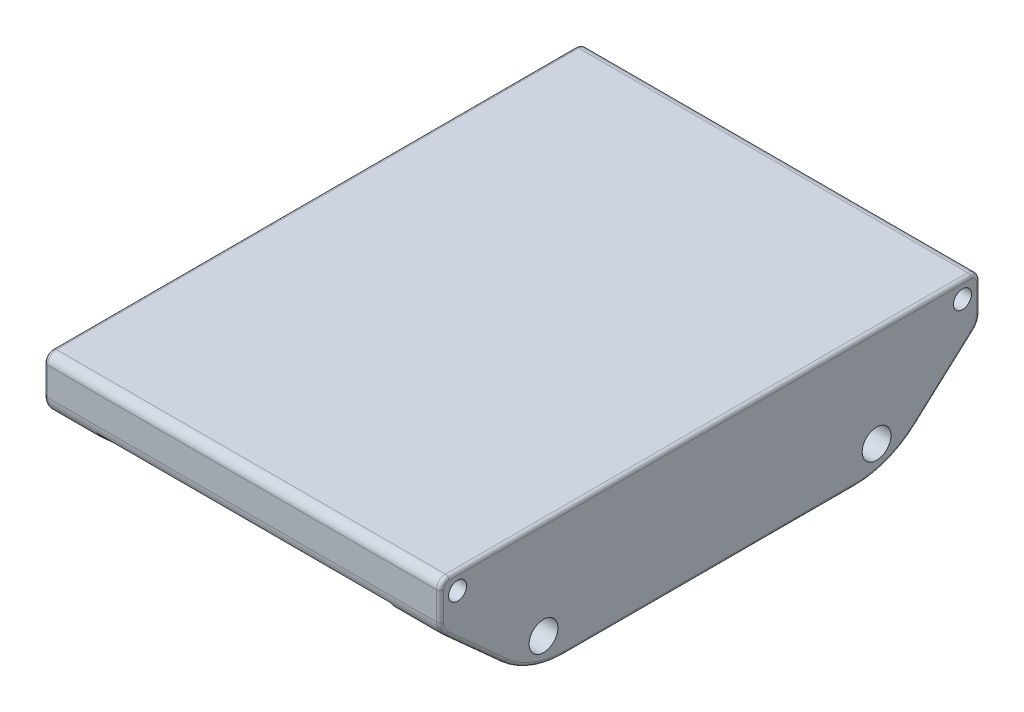
from build123d import *

# Parameters (mm, degrees)
SKETCH1_W               = 220
SKETCH1_H               = 300
BOSS_EXTRUDE1_DEPTH     = 70
SKETCH2_R               = 5
SKETCH2_R_2             = 8
CUT_EXTRUDE1_DEPTH      = 221
CHAMFER1_SIZE           = 50
CHAMFER1_SIZE2          = 45.020202215
FILLET1_R               = 5
FILLET2_R               = 10
FILLET3_R               = 50
SKETCH3_W               = 160
SKETCH3_H               = 45
CUT_EXTRUDE2_DEPTH      = 151
CUT_EXTRUDE2_DEPTH_BACK = 151
FILLET4_R               = 2
FILLET5_R               = 2


with BuildPart() as part:
    # Sketch1 → Boss-Extrude1 (new body)
    with BuildSketch(Plane(origin=(0, 0, 0), x_dir=(1, 0, 0), z_dir=(0, 1, 0))):
        Rectangle(SKETCH1_W, SKETCH1_H)
    extrude(amount=BOSS_EXTRUDE1_DEPTH)

    # Sketch2 → Cut-Extrude1 (cut, through all)
    with BuildSketch(Plane.ZY.offset(110)):
        with Locations((-140.194362572, 60.620694634)):
            Circle(SKETCH2_R)
        with Locations((-92.5, 15)):
            Circle(SKETCH2_R_2)
        with Locations((92.5, 15)):
            Circle(SKETCH2_R_2)
        with Locations((140.194362572, 60.620694634)):
            Circle(SKETCH2_R)
    extrude(amount=-CUT_EXTRUDE1_DEPTH, mode=Mode.SUBTRACT)

    # Chamfer1
    chamfer1_edges = [part.edges().sort_by_distance(p)[0] for p in [
        (0, 0, -150),
        (0, 0, 150),
    ]]
    chamfer1_side = [part.faces().sort_by_distance(p)[0] for p in [
        (0, 0, 0),
    ]]
    chamfer(chamfer1_edges, length=CHAMFER1_SIZE, length2=CHAMFER1_SIZE2, reference=chamfer1_side[0])

    # Fillet1
    fillet1_edges = [part.edges().sort_by_distance(p)[0] for p in [
        (0, 70, -150),
        (0, 70, 150),
    ]]
    fillet(fillet1_edges, radius=FILLET1_R)

    # Fillet2
    fillet2_edges = [part.edges().sort_by_distance(p)[0] for p in [
        (0, 45.020202215, 150),
        (0, 45.020202215, -150),
    ]]
    fillet(fillet2_edges, radius=FILLET2_R)

    # Fillet3
    fillet3_edges = [part.edges().sort_by_distance(p)[0] for p in [
        (0, 0, -100),
        (0, 0, 100),
    ]]
    fillet(fillet3_edges, radius=FILLET3_R)

    # Sketch3 → Cut-Extrude2 (cut, two sides)
    with BuildSketch(Plane.XY) as cut_extrude2_sk:
        with Locations((0, 22.5)):
            Rectangle(SKETCH3_W, SKETCH3_H)
    extrude(amount=CUT_EXTRUDE2_DEPTH, mode=Mode.SUBTRACT)
    extrude(cut_extrude2_sk.sketch, amount=-CUT_EXTRUDE2_DEPTH_BACK, mode=Mode.SUBTRACT)

    # Fillet4
    fillet4_edges = [part.edges().sort_by_distance(p)[0] for p in [
        (-80, 3.320978675, 98.725195725),
        (80, 3.320978675, 98.725195725),
        (80, 43.41487437, -147.956463044),
        (80, 27.44189977, -130.477317315),
        (80, 3.320978675, -98.725195725),
        (80, 27.44189977, 130.477317315),
        (80, 43.41487437, 147.956463044),
        (-80, 0, 0),
        (-80, 27.44189977, -130.477317315),
        (-80, 43.41487437, -147.956463044),
        (-80, 3.320978675, -98.725195725),
        (-80, 43.41487437, 147.956463044),
        (-80, 27.44189977, 130.477317315),
        (80, 0, 0),
    ]]
    fillet(fillet4_edges, radius=FILLET4_R)

    # Fillet5
    fillet5_edges = [part.edges().sort_by_distance(p)[0] for p in [
        (-110, 70, 0),
        (110, 70, 0),
        (-110, 57.236244534, 150),
        (-110, 57.236244534, -150),
        (-110, 68.535533906, 148.535533906),
        (-110, 68.535533906, -148.535533906),
        (110, 57.236244534, -150),
        (110, 57.236244534, 150),
        (110, 68.535533906, 148.535533906),
        (110, 68.535533906, -148.535533906),
        (-110, 27.44189977, -130.477317315),
        (-110, 45.405122637, 149.135454576),
        (-110, 45.405122637, -149.135454576),
        (110, 27.44189977, 130.477317315),
        (110, 45.405122637, 149.135454576),
        (110, 45.405122637, -149.135454576),
        (110, 0, 0),
        (-110, 0, 0),
        (110, 27.44189977, -130.477317315),
        (110, 3.320978675, 98.725195725),
        (110, 3.320978675, -98.725195725),
        (-110, 27.44189977, 130.477317315),
        (-110, 3.320978675, 98.725195725),
        (-110, 3.320978675, -98.725195725),
    ]]
    fillet(fillet5_edges, radius=FILLET5_R)


solid = part.part
